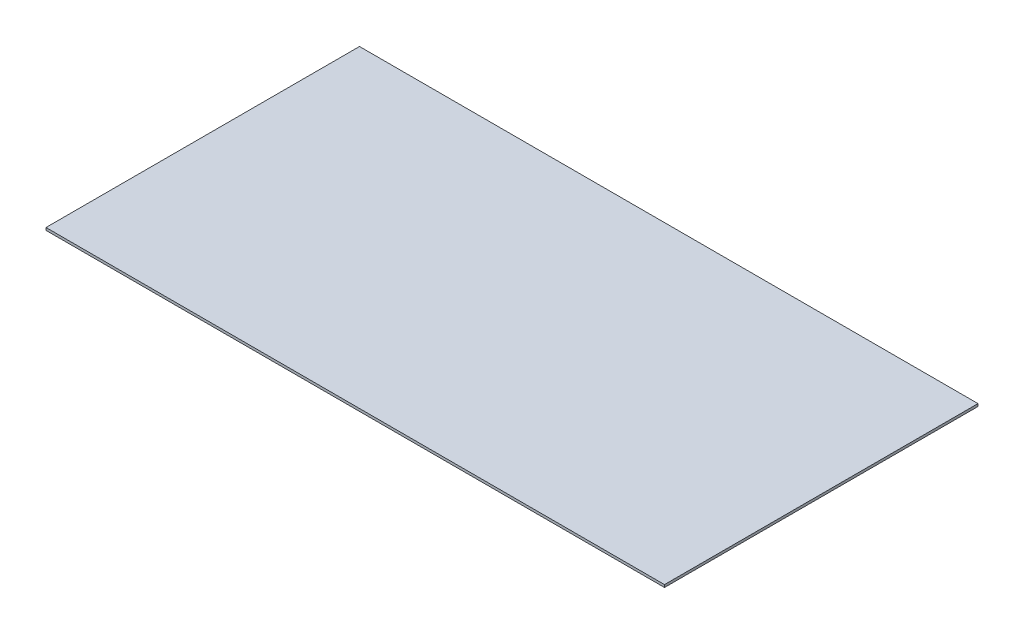
from build123d import *

# Parameters (mm, degrees)
SKETCH1_W           = 730
SKETCH1_H           = 370
BOSS_EXTRUDE1_DEPTH = 3


with BuildPart() as part:
    # Sketch1 → Boss-Extrude1 (new body)
    with BuildSketch(Plane(origin=(0, 0, 0), x_dir=(1, 0, 0), z_dir=(0, 1, 0))):
        Rectangle(SKETCH1_W, SKETCH1_H)
    extrude(amount=BOSS_EXTRUDE1_DEPTH)


solid = part.part
